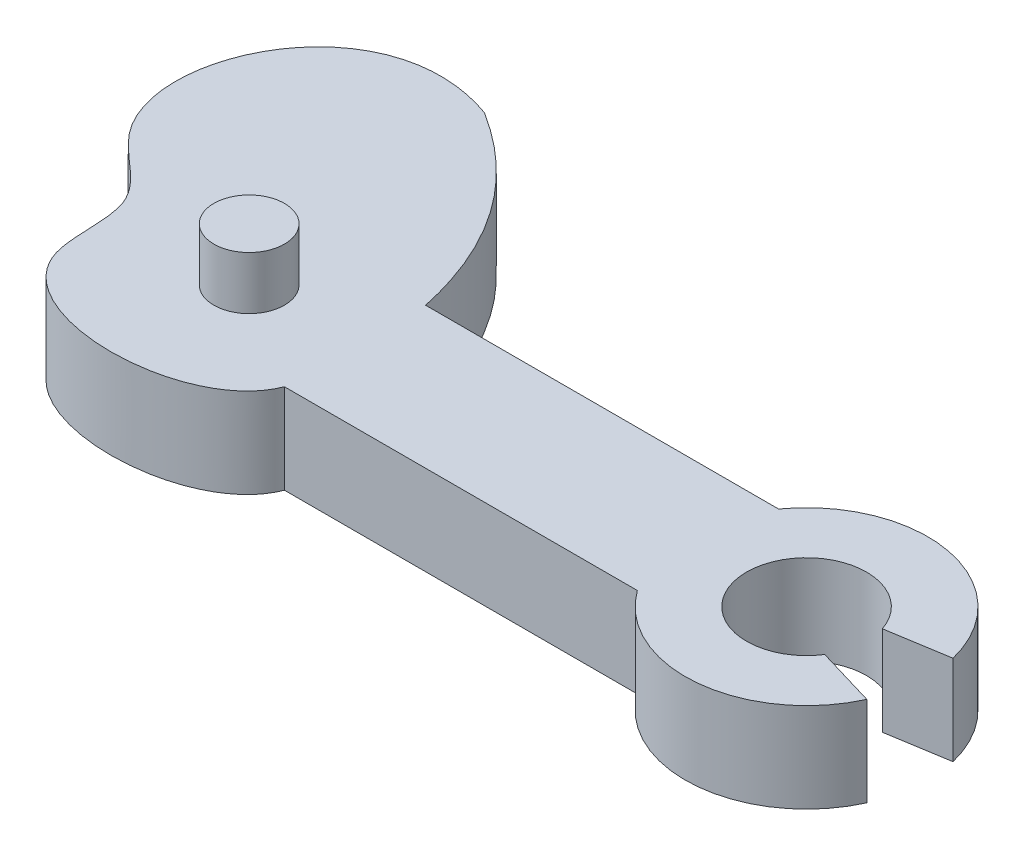
from build123d import *

# Parameters (mm, degrees)
SKETCH1_W           = 10
SKETCH1_H           = 4
BOSS_EXTRUDE2_DEPTH = 2.54
SKETCH3_R           = 1
BOSS_EXTRUDE3_DEPTH = 1.5
SKETCH4_R           = 1
BOSS_EXTRUDE5_DEPTH = 1.5


with BuildPart() as part:
    # Sketch1 → Boss-Extrude2 (new body)
    with BuildSketch(Plane(origin=(0, 0, 0), x_dir=(1, 0, 0), z_dir=(0, 1, 0))):
        with BuildLine():
            add(Edge.make_bspline(
                [(-3.892071286, 7.55845385), (-0.771451313, 5.601679727), (0, 2)],
                knots=[0, 0, 0, 1, 1, 1], degree=2))
            Line((0, 2), (0, -2))
            add(Edge.make_bspline(
                [(0, -2), (-0.807019421, -4.0986057), (-7.360800537, -4.196276699), (-6.343457725, 0.548340217), (-10.778232398, 2.929025773), (-8.051665625, 9.045483404), (-3.892071286, 7.55845385)],
                knots=[0, 0, 0, 0, 0.355860313, 0.470047608, 0.583542681, 1, 1, 1, 1], degree=3))
        make_face()
        with Locations((5, 0)):
            Rectangle(SKETCH1_W, SKETCH1_H)
        with BuildLine():
            Line((11.094, 0), (10, 0))
            Line((10, 0), (10, -2))
            ThreePointArc((10, -2), (13.128207579, -3.419757491), (15.922350304, -1.421217919))
            Line((15.922350304, -1.421217919), (14.22610231, -0.916014724))
            ThreePointArc((14.22610231, -0.916014724), (12.316807128, -1.631651606), (11.094, 0))
        make_face()
        with BuildLine():
            Line((10, 2), (10, 0))
            Line((10, 0), (11.094, 0))
            ThreePointArc((11.094, 0), (12.524636877, 1.678524205), (14.408639421, 0.531920615))
            Line((14.408639421, 0.531920615), (16.133188964, 0.810094479))
            ThreePointArc((16.133188964, 0.810094479), (13.448428406, 3.373152748), (10, 2))
        make_face()
    extrude(amount=BOSS_EXTRUDE2_DEPTH)

    # Sketch3 → Boss-Extrude3 (add)
    with BuildSketch(Plane(origin=(0, 2.54, 0), x_dir=(1, 0, 0), z_dir=(0, 1, 0))):
        with Locations((-3, 0)):
            Circle(SKETCH3_R)
    extrude(amount=BOSS_EXTRUDE3_DEPTH)

    # Sketch4 → Boss-Extrude5 (add)
    with BuildSketch(Plane(origin=(0, 0, 0), x_dir=(-1, 0, 0), z_dir=(0, -1, 0))):
        with Locations((4.872437244, 3.501336217)):
            Circle(SKETCH4_R)
    extrude(amount=BOSS_EXTRUDE5_DEPTH)


solid = part.part
